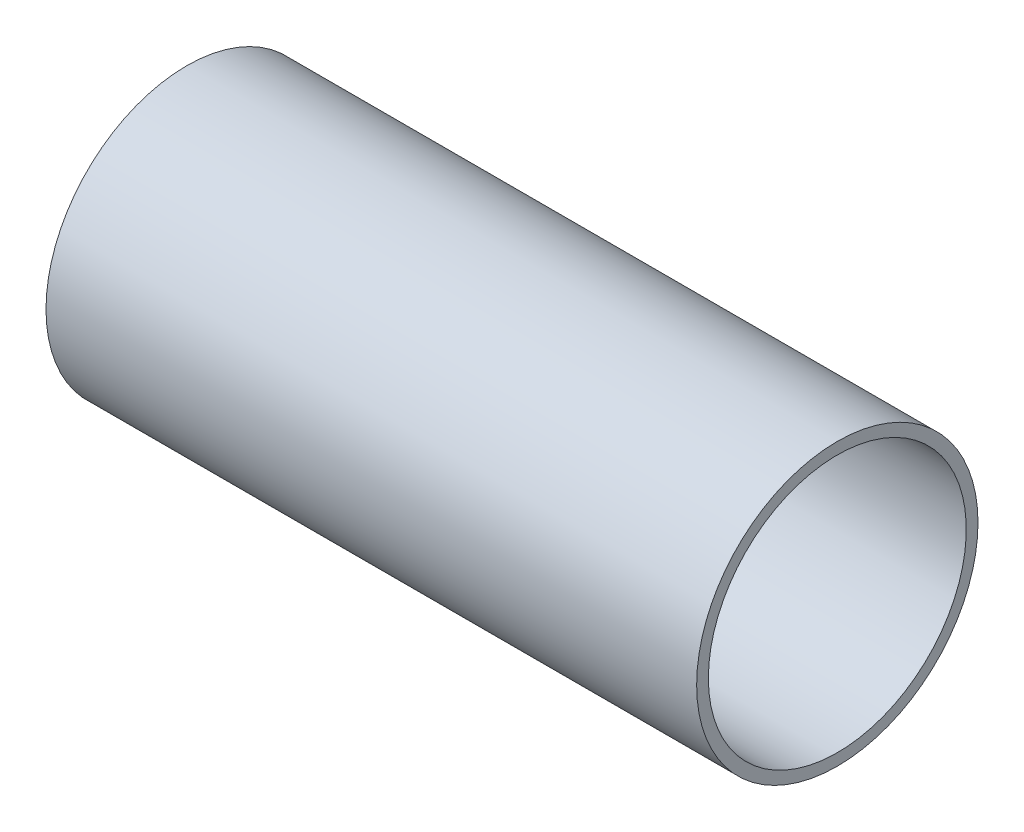
from build123d import *

# Parameters (mm, degrees)
SKETCH1_R           = 38.1
BOSS_EXTRUDE1_DEPTH = 88.10625
SHELL2_T            = -3.175


with BuildPart() as part:
    # Sketch1 → Boss-Extrude1 (new, symmetric)
    with BuildSketch(Plane(origin=(0, 0, 0), x_dir=(0, 0, -1), z_dir=(1, 0, 0))):
        with Locations(Location((0, 0, 0), (0, 0, 180))):
            Circle(SKETCH1_R)
    extrude(amount=BOSS_EXTRUDE1_DEPTH, both=True)

    # Shell2
    shell2_openings = [part.faces().sort_by_distance(p)[0] for p in [
        (88.10625, 0, 0),
        (-88.10625, 0, 0),
    ]]
    offset(amount=SHELL2_T, openings=shell2_openings, kind=Kind.INTERSECTION)


solid = part.part
